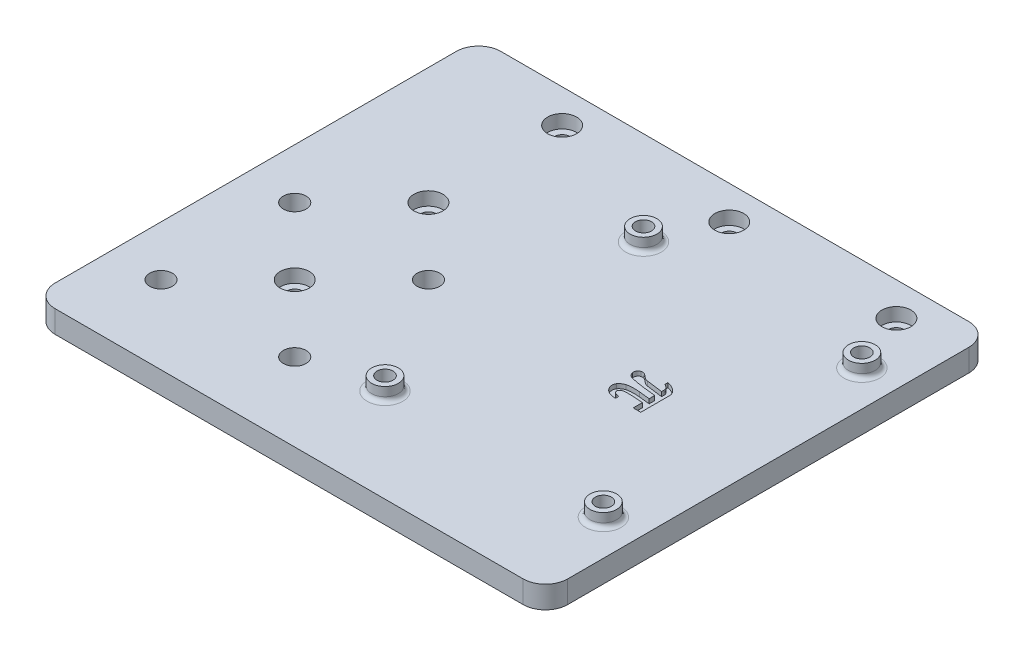
from build123d import *

# Parameters (mm, degrees)
SKETCH1_W                      = 65
SKETCH1_H                      = 100
BOSS_EXTRUDE1_DEPTH            = 5
SKETCH2_R                      = 3
BOSS_EXTRUDE2_DEPTH            = 3
F_3_6_3_6_DIAMETER_HOLE1_D     = 3.6
CBORE_FOR_M3_SHCS1_D           = 3.4
CBORE_FOR_M3_SHCS1_CBORE_D     = 6.5
CBORE_FOR_M3_SHCS1_CBORE_DEPTH = 3
SKETCH9_W                      = 100
SKETCH9_H                      = 5
BOSS_EXTRUDE3_DEPTH            = 50
CBORE_FOR_M3_SHCS2_D           = 3.4
CBORE_FOR_M3_SHCS2_CBORE_D     = 6.5
CBORE_FOR_M3_SHCS2_CBORE_DEPTH = 3
CUT_EXTRUDE1_DEPTH             = 1
FILLET1_R                      = 1
FILLET2_R                      = 5
F_5_1_5_1_DIAMETER_HOLE1_D     = 5.1


with BuildPart() as part:
    # Sketch1 → Boss-Extrude1 (new body)
    with BuildSketch(Plane(origin=(0, 0, 0), x_dir=(1, 0, 0), z_dir=(0, 1, 0))):
        with Locations((32.5, -50)):
            Rectangle(SKETCH1_W, SKETCH1_H)
    extrude(amount=BOSS_EXTRUDE1_DEPTH)

    # Sketch2 → Boss-Extrude2 (add)
    with BuildSketch(Plane(origin=(0, 5, 0), x_dir=(1, 0, 0), z_dir=(0, 1, 0))):
        with Locations(Location((8, -21, 0), (0, 0, 270))):
            Circle(SKETCH2_R)
        with Locations(Location((57, -21, 0), (0, 0, 270))):
            Circle(SKETCH2_R)
        with Locations(Location((57, -79, 0), (0, 0, 270))):
            Circle(SKETCH2_R)
        with Locations(Location((8, -79, 0), (0, 0, 270))):
            Circle(SKETCH2_R)
    extrude(amount=BOSS_EXTRUDE2_DEPTH)

    # Ø3.6 (3.6) Diameter Hole1 (through all)
    with Locations(Plane(origin=(0, 8, 0), x_dir=(1, 0, 0), z_dir=(0, 1, 0))):
        with Locations((8, -21), (57, -21), (57, -79), (8, -79)):
            Hole(F_3_6_3_6_DIAMETER_HOLE1_D / 2)

    # CBORE for M3 SHCS1 (through all)
    with Locations(Plane(origin=(0, 5, 0), x_dir=(1, 0, 0), z_dir=(0, 1, 0))):
        with Locations((13.75, -7.5), (51.25, -7.5)):
            CounterBoreHole(CBORE_FOR_M3_SHCS1_D / 2, CBORE_FOR_M3_SHCS1_CBORE_D / 2, CBORE_FOR_M3_SHCS1_CBORE_DEPTH)

    # Sketch9 → Boss-Extrude3 (add)
    with BuildSketch(Plane.ZY):
        with Locations((50, 2.5)):
            Rectangle(SKETCH9_W, SKETCH9_H)
    extrude(amount=BOSS_EXTRUDE3_DEPTH)

    # CBORE for M3 SHCS2 (through all)
    with Locations(Plane(origin=(0, 5, 0), x_dir=(1, 0, 0), z_dir=(0, 1, 0))):
        with Locations((-23.75, -67.5), (-23.75, -7.5), (-23.75, -37.5)):
            CounterBoreHole(CBORE_FOR_M3_SHCS2_D / 2, CBORE_FOR_M3_SHCS2_CBORE_D / 2, CBORE_FOR_M3_SHCS2_CBORE_DEPTH)

    # Sketch16 → Cut-Extrude1 (cut)
    with BuildSketch(Plane(origin=(0, 5, 0), x_dir=(1, 0, 0), z_dir=(0, 1, 0))):
        with BuildLine():
            Line((39.126262207, -50.847545166), (39.126262207, -49.597897606))
            add(Edge.make_bspline(
                [(39.126262207, -49.597897606), (38.887061603, -49.575713781), (38.426953933, -49.5330427), (37.765335099, -49.467029699), (37.16050318, -49.395654418), (36.608878249, -49.329176979), (36.103389832, -49.260432621), (35.637684233, -49.194155672), (35.207796553, -49.125451167), (34.693851603, -49.042468377), (34.106849427, -48.930569543), (33.65316464, -48.833024779), (33.43663372, -48.786469421)],
                knots=[0, 0, 0, 0, 1.253096053, 2.41035807, 3.468180285, 4.429891672, 5.308555075, 6.129167563, 6.883542428, 7.579384342, 8.844708592, 10, 10, 10, 10], degree=3))
            add(Edge.make_bspline(
                [(33.43663372, -48.786469421), (33.362346649, -48.767894411), (33.217288497, -48.731623541), (33.012809199, -48.653717957), (32.825678299, -48.562470211), (32.654731085, -48.453628715), (32.502165181, -48.313171441), (32.378215441, -48.129778401), (32.270782782, -47.910183348), (32.22072951, -47.746398482), (32.194209557, -47.659619598)],
                knots=[0, 0, 0, 0, 1.028706086, 2.008723763, 2.935244992, 3.824118955, 4.724963072, 5.700873389, 6.781843246, 8, 8, 8, 8], degree=3))
            add(Edge.make_bspline(
                [(32.194209557, -47.659619598), (32.184050249, -47.593155924), (32.163986257, -47.461894353), (32.185456965, -47.261992825), (32.24760698, -47.068817641), (32.345988654, -46.886281707), (32.470276431, -46.723283517), (32.612903387, -46.590894898), (32.770825068, -46.49396615), (32.885825633, -46.461994139), (32.943034973, -46.44608902)],
                knots=[0, 0, 0, 0, 1.027404461, 2.029059083, 3.048769739, 4.122307651, 5.19302046, 6.17728816, 7.093255398, 8, 8, 8, 8], degree=3))
            add(Edge.make_bspline(
                [(32.943034973, -46.44608902), (33.019790611, -46.432729059), (33.159183567, -46.408466548), (33.358775166, -46.415044291), (33.530189985, -46.45624418), (33.682659012, -46.516761006), (33.820245014, -46.588705021), (33.94106644, -46.670397622), (34.053969979, -46.753634053), (34.125488835, -46.811784665), (34.161381149, -46.840968018)],
                knots=[0, 0, 0, 0, 1.397360562, 2.537692669, 3.559369145, 4.550448304, 5.47954959, 6.34367758, 7.168761249, 8, 8, 8, 8], degree=3))
            add(Edge.make_bspline(
                [(34.161381149, -46.840968018), (34.171740761, -46.84988817), (34.20290871, -46.876725361), (34.270587507, -46.926391538), (34.365875235, -47.009106142), (34.490280901, -47.108420261), (34.623007569, -47.217425956), (34.758849499, -47.313547894), (34.885293124, -47.395630136), (35.04302611, -47.483660165), (35.248195948, -47.563686604), (35.419904702, -47.590557351), (35.50734066, -47.604240227)],
                knots=[0, 0, 0, 0, 0.26063328, 0.784141858, 1.599335041, 2.665418653, 3.819900223, 4.873162956, 5.836886495, 6.693141337, 8.316111744, 10, 10, 10, 10], degree=3))
            Line((35.50734066, -47.604240227), (39.126262207, -48.073760986))
            Line((39.126262207, -48.073760986), (39.126262207, -47.466995697))
            add(Edge.make_bspline(
                [(39.126262207, -47.466995697), (39.120615941, -47.395372643), (39.108842141, -47.246021633), (39.011762919, -47.038358034), (38.893301343, -46.84311371), (38.780591009, -46.744004371), (38.726567612, -46.696500092)],
                knots=[0, 0, 0, 0, 0.957298162, 1.996193101, 3.039551627, 4, 4, 4, 4], degree=3))
            Line((38.726567612, -46.696500092), (38.098132133, -46.282358704))
            Line((38.098132133, -46.282358704), (38.098132133, -45.608175049))
            add(Edge.make_bspline(
                [(38.098132133, -45.608175049), (38.265069197, -45.651305716), (38.590637549, -45.73542113), (39.059543061, -45.904315208), (39.510452961, -46.111726833), (39.782169404, -46.301225336), (39.9208358, -46.397933044)],
                knots=[0, 0, 0, 0, 1.033858386, 2.016278253, 2.987637474, 4, 4, 4, 4], degree=3))
            add(Edge.make_bspline(
                [(39.9208358, -46.397933044), (39.980466774, -46.441596233), (40.101066248, -46.529901979), (40.265647201, -46.68871056), (40.416093013, -46.870100588), (40.556417575, -47.068585687), (40.676744862, -47.287138148), (40.759698519, -47.527310442), (40.812591451, -47.784126696), (40.818378437, -47.961125766), (40.821352539, -48.052090797)],
                knots=[0, 0, 0, 0, 0.904302346, 1.828888262, 2.791608349, 3.786843382, 4.80268608, 5.834756118, 6.887217442, 8, 8, 8, 8], degree=3))
            Line((40.821352539, -48.052090797), (40.821352539, -54.430349731))
            Line((40.821352539, -54.430349731), (39.126262207, -54.430349731))
            Line((39.126262207, -54.430349731), (39.126262207, -52.369273987))
            add(Edge.make_bspline(
                [(39.126262207, -52.369273987), (38.824641017, -52.338588763), (38.212494456, -52.276312453), (37.278571929, -52.215269505), (36.316663871, -52.178581692), (35.66628914, -52.174105191), (35.336386948, -52.171834488)],
                knots=[0, 0, 0, 0, 0.958130554, 1.944546155, 2.957372268, 4, 4, 4, 4], degree=3))
            add(Edge.make_bspline(
                [(35.336386948, -52.171834488), (35.216918961, -52.176632011), (34.979958118, -52.18614774), (34.699390908, -52.267738632), (34.498680733, -52.345822532), (34.376377238, -52.399383952), (34.282754213, -52.45111856), (34.234840863, -52.489924695), (34.214352722, -52.506518517)],
                knots=[0, 0, 0, 0, 1.804721428, 3.579605919, 4.387653081, 5.067635593, 5.601313335, 6, 6, 6, 6], degree=3))
            add(Edge.make_bspline(
                [(34.214352722, -52.506518517), (34.158438507, -52.572803412), (34.054075473, -52.696523165), (33.974254217, -52.882970365), (33.965236632, -53.035635661), (33.99855982, -53.155268657), (34.063359986, -53.281985338), (34.125363446, -53.363077846), (34.158973351, -53.407035255)],
                knots=[0, 0, 0, 0, 1.530222605, 2.85613729, 3.495539136, 4.19786485, 5.023125643, 6, 6, 6, 6], degree=3))
            add(Edge.make_bspline(
                [(34.158973351, -53.407035255), (34.202678445, -53.453603851), (34.288209182, -53.54473845), (34.449483531, -53.638340717), (34.618180335, -53.696546772), (34.801341682, -53.734863252), (35.02056346, -53.757230953), (35.181594158, -53.781052837), (35.27378418, -53.794690857)],
                knots=[0, 0, 0, 0, 0.943448386, 1.846325613, 2.731669575, 3.584362821, 4.617048522, 6, 6, 6, 6], degree=3))
            Line((35.27378418, -53.794690857), (35.27378418, -54.543516273))
            add(Edge.make_bspline(
                [(35.27378418, -54.543516273), (35.145259799, -54.539686724), (34.899665229, -54.532368918), (34.549534649, -54.49381644), (34.23492324, -54.435411311), (33.95485327, -54.352646637), (33.704937688, -54.251951832), (33.47764334, -54.142729191), (33.274451352, -54.017945692), (33.089768771, -53.886609091), (32.927584898, -53.741089605), (32.786131125, -53.584968182), (32.654824603, -53.424803574), (32.58524624, -53.30689432), (32.550563774, -53.248120537)],
                knots=[0, 0, 0, 0, 1.463419428, 2.796417783, 4.006075808, 5.101867847, 6.114868065, 7.071137589, 7.969092879, 8.826327314, 9.648155468, 10.443549341, 11.224161887, 12, 12, 12, 12], degree=3))
            add(Edge.make_bspline(
                [(32.550563774, -53.248120537), (32.520790697, -53.193492864), (32.459254397, -53.080585998), (32.397200219, -52.890384649), (32.348206864, -52.6819503), (32.320086722, -52.457698844), (32.315640727, -52.227756787), (32.34661926, -52.004027153), (32.413206209, -51.79241002), (32.487069025, -51.66662071), (32.524077988, -51.603593979)],
                knots=[0, 0, 0, 0, 0.865492594, 1.788838003, 2.776551332, 3.847715376, 4.932865467, 5.972249091, 6.983995453, 8, 8, 8, 8], degree=3))
            add(Edge.make_bspline(
                [(32.524077988, -51.603593979), (32.599388708, -51.507318221), (32.75324726, -51.310628445), (33.055018494, -51.068656229), (33.409086865, -50.860800161), (33.672452045, -50.758731497), (33.809842529, -50.705485039)],
                knots=[0, 0, 0, 0, 0.918076197, 1.875614441, 2.891765566, 4, 4, 4, 4], degree=3))
            add(Edge.make_bspline(
                [(33.809842529, -50.705485039), (33.898631758, -50.682441773), (34.087470798, -50.633432807), (34.395240763, -50.584968257), (34.740993079, -50.551926433), (35.248657148, -50.532699083), (35.895954097, -50.531314455), (36.413618911, -50.570608952), (36.667899666, -50.589910698)],
                knots=[0, 0, 0, 0, 0.574329406, 1.22149743, 1.948877103, 2.749030755, 4.403100056, 6, 6, 6, 6], degree=3))
            Line((36.667899666, -50.589910698), (39.126262207, -50.847545166))
        make_face()
    extrude(amount=-CUT_EXTRUDE1_DEPTH, mode=Mode.SUBTRACT)

    # Fillet1
    fillet1_edges = [part.edges().sort_by_distance(p)[0] for p in [
        (8, 5, 18),
        (57, 5, 18),
        (57, 5, 76),
        (8, 5, 76),
    ]]
    fillet(fillet1_edges, radius=FILLET1_R)

    # Fillet2
    fillet2_edges = [part.edges().sort_by_distance(p)[0] for p in [
        (-50, 2.5, 0),
        (-50, 2.5, 100),
        (65, 2.5, 0),
        (65, 2.5, 100),
    ]]
    fillet(fillet2_edges, radius=FILLET2_R)

    # Ø5.1 (5.1) Diameter Hole1 (through all)
    with Locations(Plane(origin=(0, 5, 0), x_dir=(1, 0, 0), z_dir=(0, 1, 0))):
        with Locations((-38.75, -82.5), (-8.75, -52.5), (-38.75, -52.5), (-8.75, -82.5)):
            Hole(F_5_1_5_1_DIAMETER_HOLE1_D / 2)


solid = part.part
